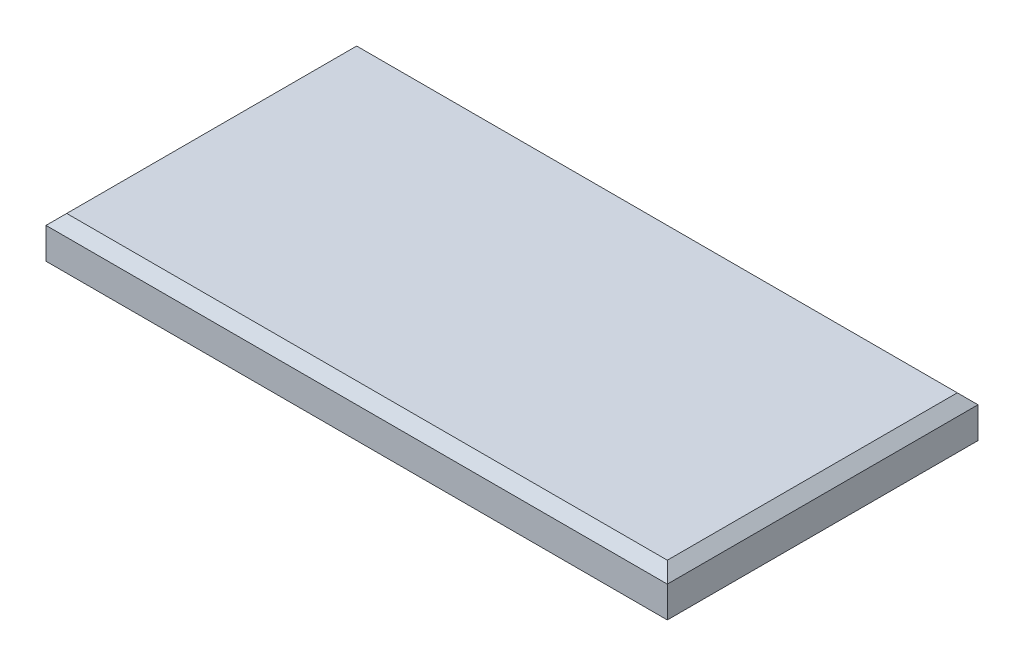
from build123d import *

# Parameters (mm, degrees)
SKETCH1_W           = 60
SKETCH1_H           = 30
BOSS_EXTRUDE1_DEPTH = 4
SHELL1_T            = -2
SKETCH2_R           = 2
BOSS_EXTRUDE2_DEPTH = 10
FILLET1_R           = 1
CHAMFER1_SIZE       = 1


with BuildPart() as part:
    # Sketch1 → Boss-Extrude1 (new body)
    with BuildSketch(Plane(origin=(0, 0, 0), x_dir=(1, 0, 0), z_dir=(0, 1, 0))):
        Rectangle(SKETCH1_W, SKETCH1_H)
    extrude(amount=BOSS_EXTRUDE1_DEPTH)

    # Shell1
    shell1_openings = [part.faces().sort_by_distance(p)[0] for p in [
        (0, 0, 0),
    ]]
    offset(amount=SHELL1_T, openings=shell1_openings, kind=Kind.INTERSECTION)

    # Sketch2 → Boss-Extrude2 (add)
    with BuildSketch(Plane.XZ.offset(-2)):
        with Locations((-15, 0)):
            Circle(SKETCH2_R)
        with Locations((15, 0)):
            Circle(SKETCH2_R)
    extrude(amount=BOSS_EXTRUDE2_DEPTH)

    # Fillet1
    fillet1_edges = [part.edges().sort_by_distance(p)[0] for p in [
        (-17, -8, 0),
        (13, -8, 0),
    ]]
    fillet(fillet1_edges, radius=FILLET1_R)

    # Chamfer1
    chamfer1_edges = [part.edges().sort_by_distance(p)[0] for p in [
        (-30, 4, 0),
        (0, 4, 15),
        (30, 4, 0),
        (0, 4, -15),
    ]]
    chamfer(chamfer1_edges, length=CHAMFER1_SIZE)


solid = part.part
